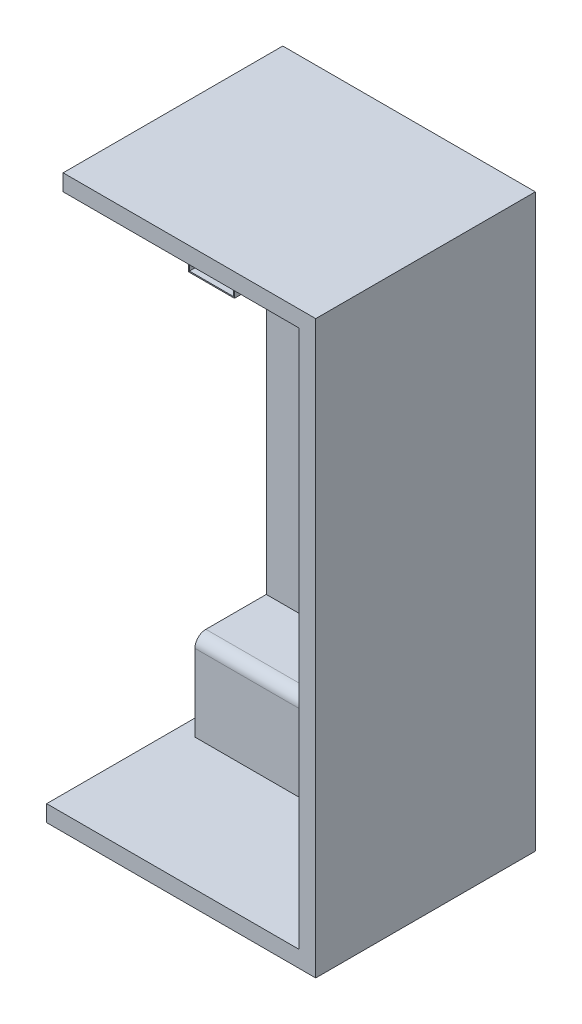
from build123d import *

# Parameters (mm, degrees)
SKETCH1_W           = 490
SKETCH1_H           = 1040
SKETCH1_W_2         = 430
SKETCH1_H_2         = 980
BOSS_EXTRUDE1_DEPTH = 370
SKETCH2_W           = 490
SKETCH2_H           = 1040
BOSS_EXTRUDE2_DEPTH = 30
SKETCH3_W           = 430
SKETCH3_H           = 160
BOSS_EXTRUDE3_DEPTH = 130
FILLET1_R           = 20
SKETCH5_W           = 30
SKETCH5_H           = 1010
CUT_EXTRUDE2_DEPTH  = 400
SKETCH7_R           = 3
BOSS_EXTRUDE4_DEPTH = 50
SKETCH8_W           = 84
SKETCH8_H           = 84
SKETCH8_W_2         = 80
SKETCH8_H_2         = 80
BOSS_EXTRUDE5_DEPTH = 300
SKETCH9_W           = 84
SKETCH9_H           = 82
CUT_EXTRUDE3_DEPTH  = 100


with BuildPart() as part:
    # Sketch1 → Boss-Extrude1 (new body)
    with BuildSketch(Plane.XY):
        Rectangle(SKETCH1_W, SKETCH1_H)
        Rectangle(SKETCH1_W_2, SKETCH1_H_2, mode=Mode.SUBTRACT)
    extrude(amount=BOSS_EXTRUDE1_DEPTH)

    # Sketch2 → Boss-Extrude2 (add)
    with BuildSketch(Plane(origin=(0, 0, 0), x_dir=(-1, 0, 0), z_dir=(0, 0, -1))):
        Rectangle(SKETCH2_W, SKETCH2_H)
    extrude(amount=BOSS_EXTRUDE2_DEPTH)

    # Sketch3 → Boss-Extrude3 (add)
    with BuildSketch(Plane.XY):
        with Locations((0, -410)):
            Rectangle(SKETCH3_W, SKETCH3_H)
    extrude(amount=BOSS_EXTRUDE3_DEPTH)

    # Fillet1
    fillet1_edges = [part.edges().sort_by_distance(p)[0] for p in [
        (0, -330, 130),
    ]]
    fillet(fillet1_edges, radius=FILLET1_R)

    # Sketch5 → Cut-Extrude2 (cut)
    with BuildSketch(Plane.XY.offset(370)):
        with Locations((-230, 15)):
            Rectangle(SKETCH5_W, SKETCH5_H)
    extrude(amount=-CUT_EXTRUDE2_DEPTH, mode=Mode.SUBTRACT)

    # Sketch7 → Boss-Extrude4 (add)
    with BuildSketch(Plane.ZY.offset(-215)):
        with Locations((160, 280)):
            Circle(SKETCH7_R)
        with Locations((160, 160)):
            Circle(SKETCH7_R)
        with Locations((160, 40)):
            Circle(SKETCH7_R)
        with Locations((160, -80)):
            Circle(SKETCH7_R)
        with Locations((160, -200)):
            Circle(SKETCH7_R)
    extrude(amount=BOSS_EXTRUDE4_DEPTH)

    # Sketch8 → Boss-Extrude5 (add)
    with BuildSketch(Plane.XY):
        with Locations((-15, 450)):
            Rectangle(SKETCH8_W, SKETCH8_H)
        with Locations((-15, 450)):
            Rectangle(SKETCH8_W_2, SKETCH8_H_2, mode=Mode.SUBTRACT)
    extrude(amount=BOSS_EXTRUDE5_DEPTH)

    # Sketch9 → Cut-Extrude3 (cut)
    with BuildSketch(Plane.XY):
        with Locations((-15, 449)):
            Rectangle(SKETCH9_W, SKETCH9_H)
    extrude(amount=CUT_EXTRUDE3_DEPTH, mode=Mode.SUBTRACT)


solid = part.part
